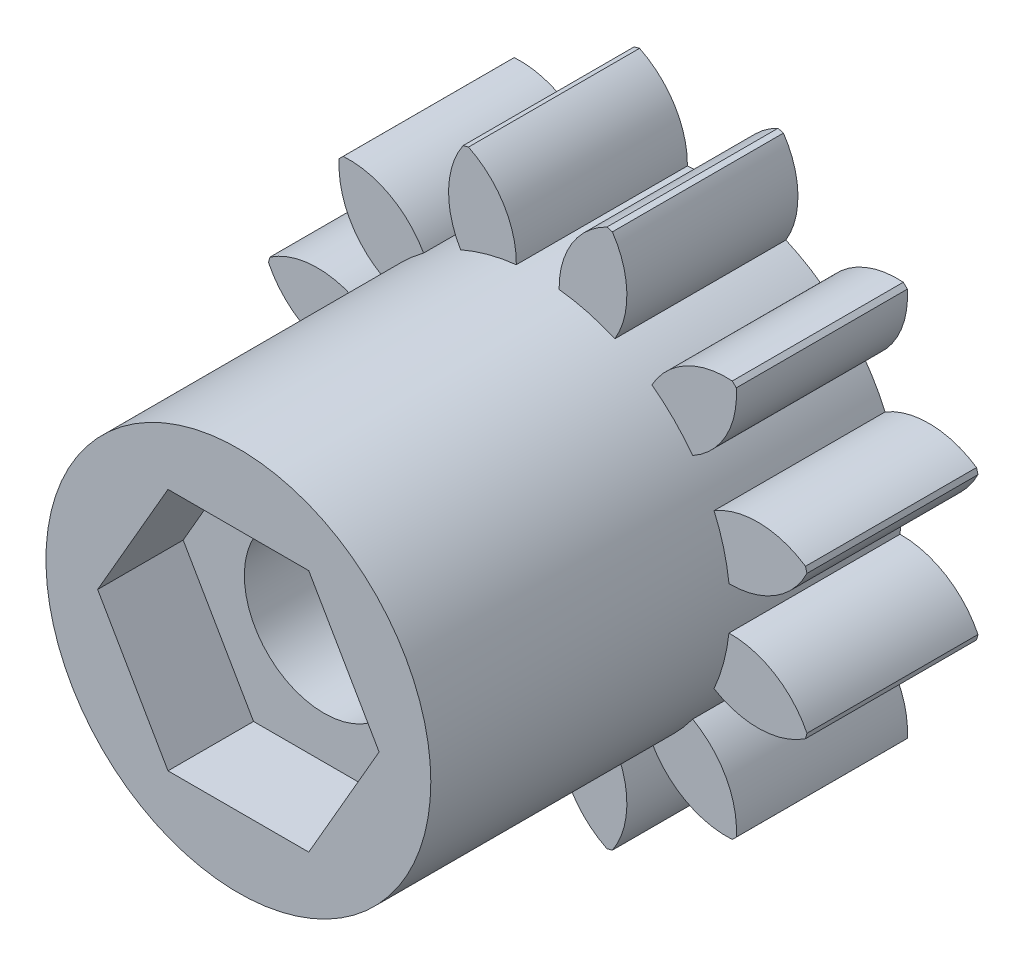
from build123d import *

# Parameters (mm, degrees)
SKETCH1_R           = 6.5
SKETCH1_R_2         = 1
BOSS_EXTRUDE1_DEPTH = 4
CUT_EXTRUDE2_DEPTH  = 11.024968828
CIRPATTERN2_COUNT   = 12
SKETCH11_R          = 4.5
BOSS_EXTRUDE2_DEPTH = 11
CUT_EXTRUDE3_START  = 11
CUT_EXTRUDE3_DEPTH  = 2
CUT_EXTRUDE4_DEPTH  = 15.151353444


with BuildPart() as part:
    # Sketch1 → Boss-Extrude1 (new body)
    with BuildSketch(Plane.XY):
        Circle(SKETCH1_R)
        Circle(SKETCH1_R_2, mode=Mode.SUBTRACT)
    extrude(amount=BOSS_EXTRUDE1_DEPTH)

    # Sketch4 → Cut-Extrude2 (cut, through all)
    with BuildSketch(Plane.XY):
        with BuildLine():
            ThreePointArc((-0.500194414, 4.472114215), (0, 4.5), (0.500194414, 4.472114215))
            ThreePointArc((0.500194414, 4.472114215), (1.113314535, 5.941215952), (2.604960982, 6.497243899))
            ThreePointArc((2.604960982, 6.497243899), (0, 7), (-2.604960982, 6.497243899))
            ThreePointArc((-2.604960982, 6.497243899), (-1.123395838, 5.950848366), (-0.5, 4.5))
            ThreePointArc((-0.5, 4.5), (-0.500048604, 4.486056768), (-0.500194414, 4.472114215))
        make_face()
    cut_extrude2 = extrude(amount=CUT_EXTRUDE2_DEPTH, mode=Mode.SUBTRACT)

    # CirPattern2: Cut-Extrude2 ×12 about axis
    cirpattern2_axis = Axis((0, 0, 4), (0, 0, -1))
    for i in range(1, CIRPATTERN2_COUNT):
        add(cut_extrude2.rotate(cirpattern2_axis, i * 360 / CIRPATTERN2_COUNT), mode=Mode.SUBTRACT)

    # Sketch11 → Boss-Extrude2 (add)
    with BuildSketch(Plane.XY):
        Circle(SKETCH11_R)
    extrude(amount=BOSS_EXTRUDE2_DEPTH)

    # Sketch12 → Cut-Extrude3 (cut)
    with BuildSketch(Plane.XY.offset(CUT_EXTRUDE3_START)):
        Polygon((3.290896534, 0), (1.645448267, 2.85), (-1.645448267, 2.85), (-3.290896534, 0), (-1.645448267, -2.85), (1.645448267, -2.85), align=None)
    extrude(amount=-CUT_EXTRUDE3_DEPTH, mode=Mode.SUBTRACT)

    # Sketch13 → Cut-Extrude4 (cut, through all)
    with BuildSketch(Plane.XY):
        with BuildLine():
            ThreePointArc((-1.6, 0.95), (0, -1.860779407), (1.6, 0.95))
            Line((1.6, 0.95), (-1.6, 0.95))
        make_face()
    extrude(amount=CUT_EXTRUDE4_DEPTH, mode=Mode.SUBTRACT)


solid = part.part
